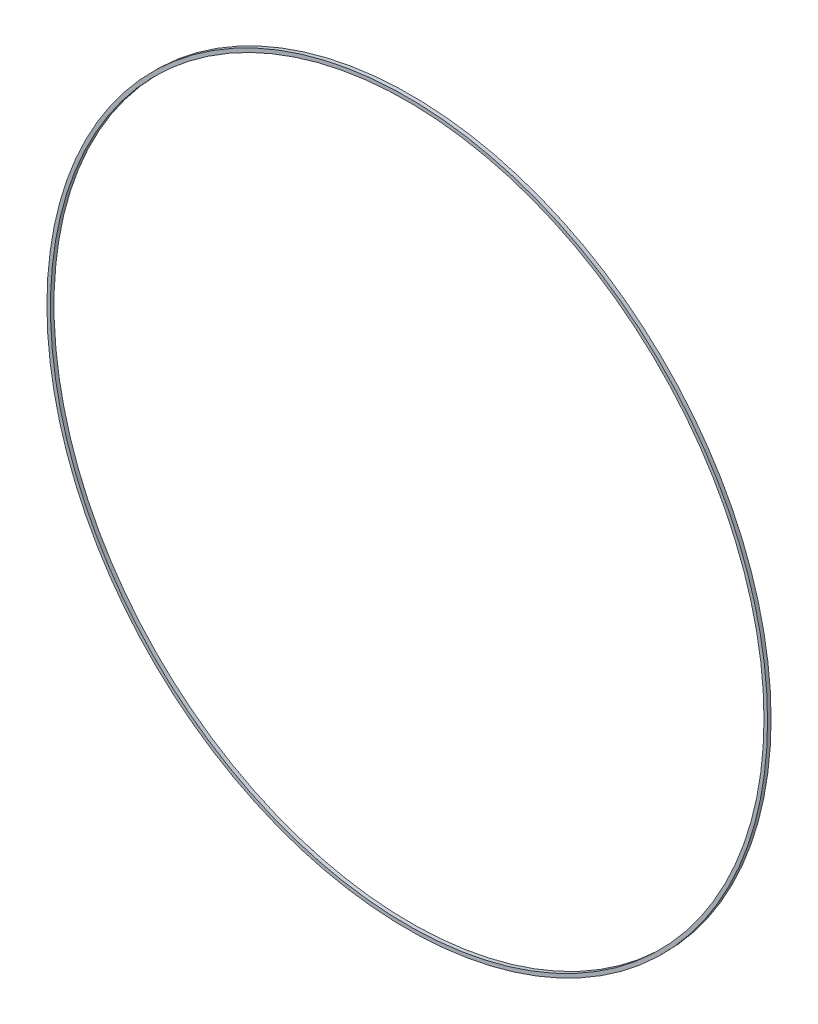
from build123d import *

# Parameters (mm, degrees)
SKETCH2_R           = 203
BOSS_EXTRUDE1_DEPTH = 2
SKETCH3_R           = 201
CUT_EXTRUDE1_DEPTH  = 3


with BuildPart() as part:
    # Sketch2 → Boss-Extrude1 (new body)
    with BuildSketch(Plane.XY):
        Circle(SKETCH2_R)
    extrude(amount=BOSS_EXTRUDE1_DEPTH)

    # Sketch3 → Cut-Extrude1 (cut, through all)
    with BuildSketch(Plane.XY.offset(2)):
        Circle(SKETCH3_R)
    extrude(amount=-CUT_EXTRUDE1_DEPTH, mode=Mode.SUBTRACT)


solid = part.part
